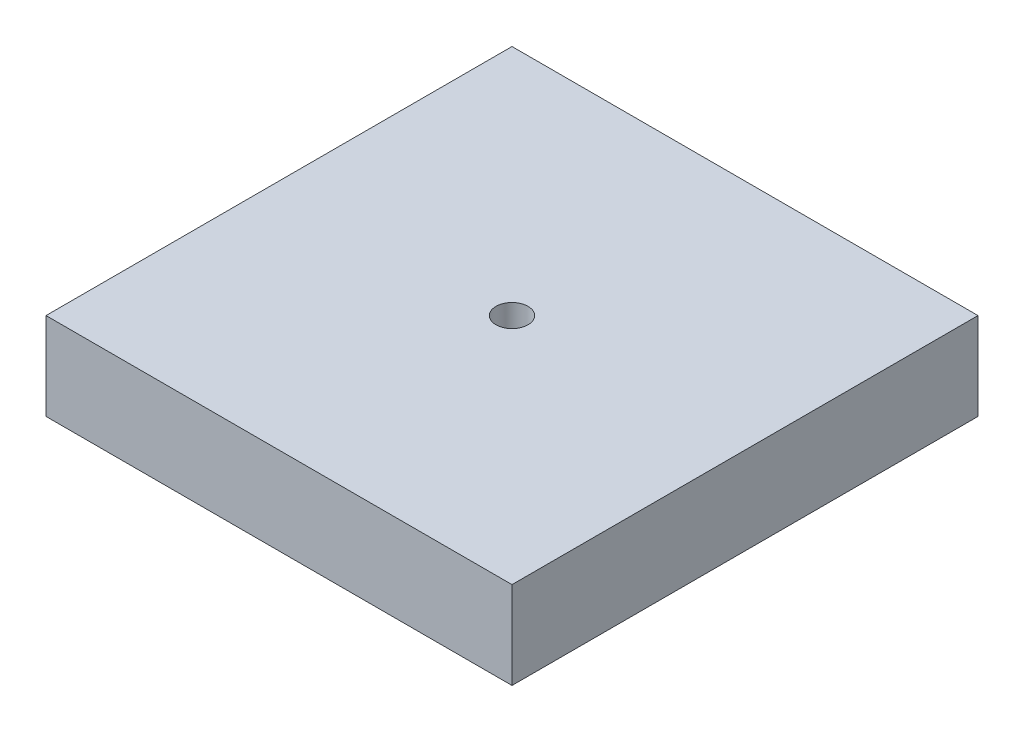
from build123d import *

# Parameters (mm, degrees)
SKETCH1_W               = 101.6
SKETCH1_H               = 101.6
BOSS_EXTRUDE1_DEPTH     = 19.05
SKETCH2_R               = 3.4925
CUT_EXTRUDE1_DEPTH      = 1
CUT_EXTRUDE1_DEPTH_BACK = 20.05


with BuildPart() as part:
    # Sketch1 → Boss-Extrude1 (new body)
    with BuildSketch(Plane(origin=(0, 0, 0), x_dir=(1, 0, 0), z_dir=(0, 1, 0))):
        Rectangle(SKETCH1_W, SKETCH1_H)
    extrude(amount=BOSS_EXTRUDE1_DEPTH)

    # Sketch2 → Cut-Extrude1 (cut, two sides)
    with BuildSketch(Plane(origin=(0, 19.05, 0), x_dir=(1, 0, 0), z_dir=(0, 1, 0))) as cut_extrude1_sk:
        Circle(SKETCH2_R)
    extrude(amount=CUT_EXTRUDE1_DEPTH, mode=Mode.SUBTRACT)
    extrude(cut_extrude1_sk.sketch, amount=-CUT_EXTRUDE1_DEPTH_BACK, mode=Mode.SUBTRACT)


solid = part.part
